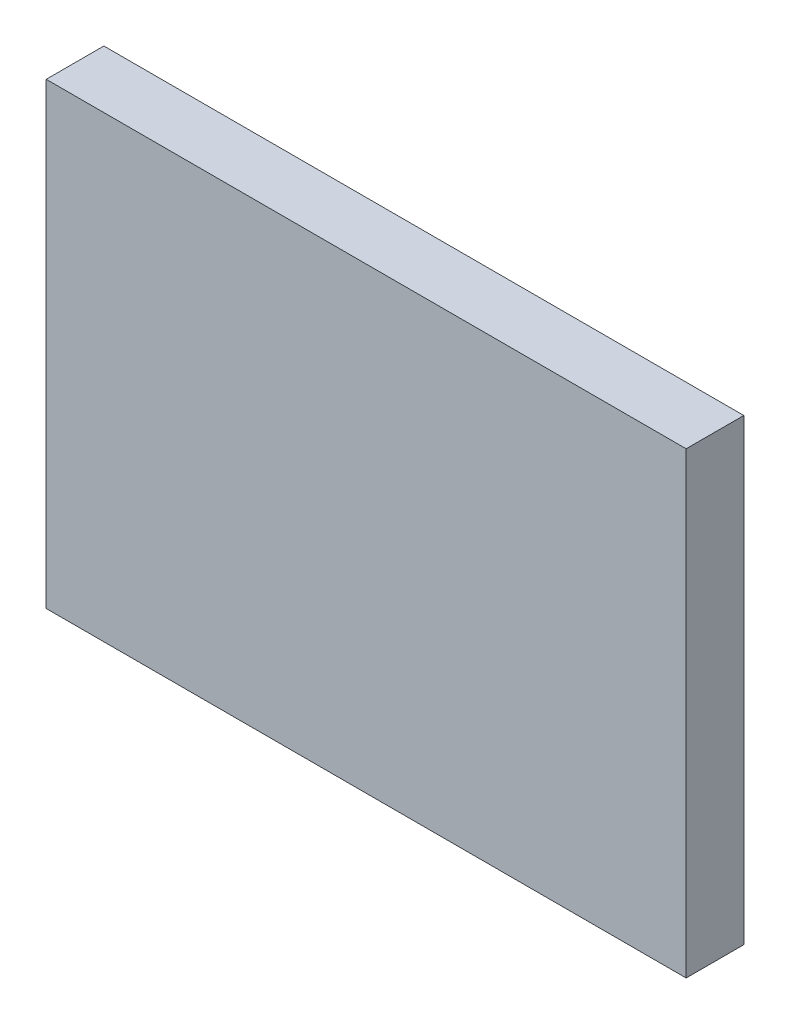
from build123d import *

# Parameters (mm, degrees)
SKETCH1_W           = 44.4
SKETCH1_H           = 31.8
BOSS_EXTRUDE2_DEPTH = 4


with BuildPart() as part:
    # Sketch1 → Boss-Extrude2 (new body)
    with BuildSketch(Plane.XY):
        with Locations((-1.190382364, 2.18320694)):
            Rectangle(SKETCH1_W, SKETCH1_H)
    extrude(amount=BOSS_EXTRUDE2_DEPTH)


solid = part.part
